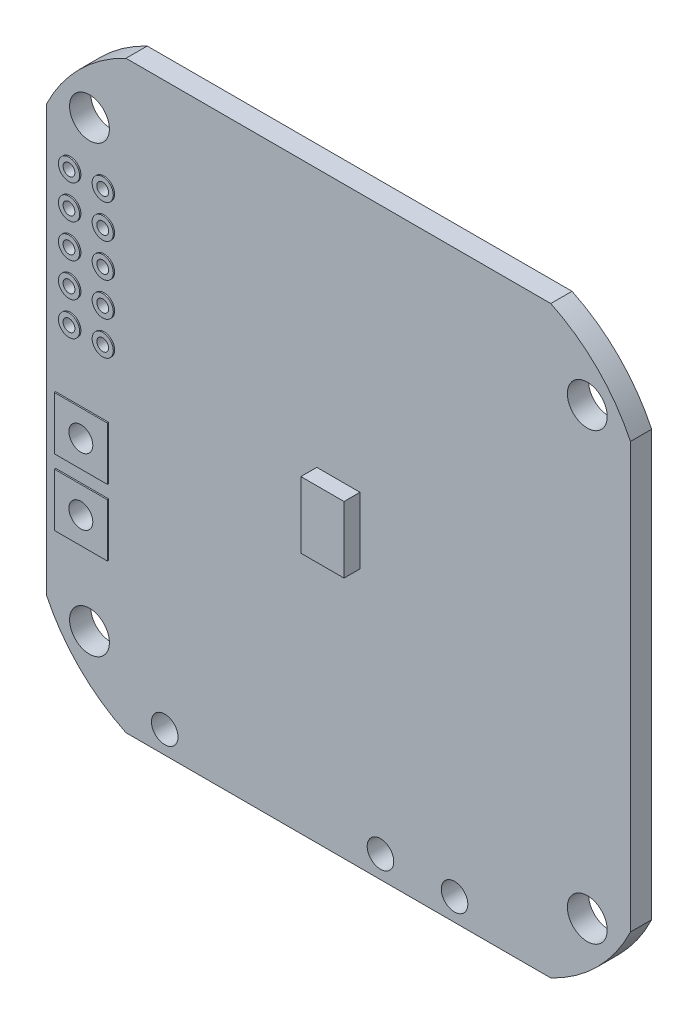
from build123d import *

# Parameters (mm, degrees)
SALIENTE_EXTRUIR1_DEPTH    = 0.8
CROQUIS2_R                 = 1.5
CORTAR_EXTRUIR1_DEPTH      = 2.6
CROQUIS3_W                 = 3.25
CROQUIS3_H                 = 5
SALIENTE_EXTRUIR2_DEPTH    = 1.2
CROQUIS4_R                 = 0.445
CORTAR_EXTRUIR2_DEPTH      = 3.8
CROQUIS5_R                 = 0.79739254
CROQUIS5_R_2               = 0.445
CROQUIS5_W                 = 4
CROQUIS5_H                 = 4
SALIENTE_EXTRUIR3_DEPTH    = 0.9
CROQUIS6_R                 = 0.9
CORTAR_EXTRUIR3_DEPTH      = 1
CORTAR_EXTRUIR3_DEPTH_BACK = 3.9
CROQUIS7_R                 = 1
CORTAR_EXTRUIR4_DEPTH      = 10
CROQUIS8_W                 = 3
CROQUIS8_H                 = 2.5
SALIENTE_EXTRUIR4_DEPTH    = 1.2
CROQUIS9_R                 = 0.75
SALIENTE_EXTRUIR5_DEPTH    = 0.8
CROQUIS10_W                = 5
CROQUIS10_H                = 5
SALIENTE_EXTRUIR6_DEPTH    = 0.9
CROQUIS11_R                = 1
SALIENTE_EXTRUIR7_DEPTH    = 0.1
SALIENTE_EXTRUIR8_DEPTH    = 0.75


with BuildPart() as part:
    # Croquis1 → Saliente-Extruir1 (new body, symmetric)
    with BuildSketch(Plane.XY):
        with BuildLine():
            Line((-22, 16), (-22, -16))
            ThreePointArc((-22, -16), (-19.513773424, -19.513773424), (-16, -22))
            Line((-16, -22), (16, -22))
            ThreePointArc((16, -22), (19.513773424, -19.513773424), (22, -16))
            Line((22, -16), (22, 16))
            ThreePointArc((22, 16), (19.513773424, 19.513773424), (16, 22))
            Line((16, 22), (-16, 22))
            ThreePointArc((-16, 22), (-19.513773424, 19.513773424), (-22, 16))
        make_face()
    extrude(amount=SALIENTE_EXTRUIR1_DEPTH, both=True)

    # Croquis2 → Cortar-Extruir1 (cut, through all)
    with BuildSketch(Plane.XY.offset(0.8)):
        with Locations((-18.75, 16.75)):
            Circle(CROQUIS2_R)
        with Locations((18.75, 16.75)):
            Circle(CROQUIS2_R)
        with Locations((18.75, -16.75)):
            Circle(CROQUIS2_R)
        with Locations((-18.75, -16.75)):
            Circle(CROQUIS2_R)
    extrude(amount=-CORTAR_EXTRUIR1_DEPTH, mode=Mode.SUBTRACT)

    # Croquis3 → Saliente-Extruir2 (add)
    with BuildSketch(Plane.XY.offset(0.8)):
        Rectangle(CROQUIS3_W, CROQUIS3_H)
    extrude(amount=SALIENTE_EXTRUIR2_DEPTH)

    # Croquis4 → Cortar-Extruir2 (cut, through all)
    with BuildSketch(Plane(origin=(0, 0, -0.8), x_dir=(-1, 0, 0), z_dir=(0, 0, -1))):
        with Locations((17.653, 12.7)):
            Circle(CROQUIS4_R)
        with Locations((20.193, 12.7)):
            Circle(CROQUIS4_R)
        with Locations((20.193, 10.16)):
            Circle(CROQUIS4_R)
        with Locations((20.193, 7.62)):
            Circle(CROQUIS4_R)
        with Locations((20.193, 5.08)):
            Circle(CROQUIS4_R)
        with Locations((20.193, 2.54)):
            Circle(CROQUIS4_R)
        with Locations((17.653, 10.16)):
            Circle(CROQUIS4_R)
        with Locations((17.653, 7.62)):
            Circle(CROQUIS4_R)
        with Locations((17.653, 5.08)):
            Circle(CROQUIS4_R)
        with Locations((17.653, 2.54)):
            Circle(CROQUIS4_R)
    extrude(amount=-CORTAR_EXTRUIR2_DEPTH, mode=Mode.SUBTRACT)

    # Croquis5 → Saliente-Extruir3 (add, symmetric)
    with BuildSketch(Plane.XY):
        with Locations((-17.653, 2.54)):
            Circle(CROQUIS5_R)
        with Locations((-17.653, 2.54)):
            Circle(CROQUIS5_R_2, mode=Mode.SUBTRACT)
        with Locations((-20.193, 2.54)):
            Circle(CROQUIS5_R)
        with Locations((-20.193, 2.54)):
            Circle(CROQUIS5_R_2, mode=Mode.SUBTRACT)
        with Locations((-20.193, 5.08)):
            Circle(CROQUIS5_R)
        with Locations((-20.193, 5.08)):
            Circle(CROQUIS5_R_2, mode=Mode.SUBTRACT)
        with Locations((-17.653, 5.08)):
            Circle(CROQUIS5_R)
        with Locations((-17.653, 5.08)):
            Circle(CROQUIS5_R_2, mode=Mode.SUBTRACT)
        with Locations((-17.653, 7.62)):
            Circle(CROQUIS5_R)
        with Locations((-17.653, 7.62)):
            Circle(CROQUIS5_R_2, mode=Mode.SUBTRACT)
        with Locations((-17.653, 10.16)):
            Circle(CROQUIS5_R)
        with Locations((-17.653, 10.16)):
            Circle(CROQUIS5_R_2, mode=Mode.SUBTRACT)
        with Locations((-20.193, 7.62)):
            Circle(CROQUIS5_R)
        with Locations((-20.193, 7.62)):
            Circle(CROQUIS5_R_2, mode=Mode.SUBTRACT)
        with Locations((-20.193, 10.16)):
            Circle(CROQUIS5_R)
        with Locations((-20.193, 10.16)):
            Circle(CROQUIS5_R_2, mode=Mode.SUBTRACT)
        with Locations((-17.653, 12.7)):
            Circle(CROQUIS5_R)
        with Locations((-17.653, 12.7)):
            Circle(CROQUIS5_R_2, mode=Mode.SUBTRACT)
        with Locations((-20.193, 12.7)):
            Circle(CROQUIS5_R)
        with Locations((-20.193, 12.7)):
            Circle(CROQUIS5_R_2, mode=Mode.SUBTRACT)
        with Locations((-19.3, -4.4)):
            Rectangle(CROQUIS5_W, CROQUIS5_H)
        with Locations((-19.3, -9.4)):
            Rectangle(CROQUIS5_W, CROQUIS5_H)
    extrude(amount=SALIENTE_EXTRUIR3_DEPTH, both=True)

    # Croquis6 → Cortar-Extruir3 (cut, two sides)
    with BuildSketch(Plane(origin=(0, 0, -0.9), x_dir=(-1, 0, 0), z_dir=(0, 0, -1))) as cortar_extruir3_sk:
        with Locations((19.3, -4.4)):
            Circle(CROQUIS6_R)
        with Locations((19.3, -9.4)):
            Circle(CROQUIS6_R)
    extrude(amount=CORTAR_EXTRUIR3_DEPTH, mode=Mode.SUBTRACT)
    extrude(cortar_extruir3_sk.sketch, amount=-CORTAR_EXTRUIR3_DEPTH_BACK, mode=Mode.SUBTRACT)

    # Croquis7 → Cortar-Extruir4 (cut)
    with BuildSketch(Plane(origin=(0, 0, -0.8), x_dir=(-1, 0, 0), z_dir=(0, 0, -1))):
        with Locations((-8.75, -20.32)):
            Circle(CROQUIS7_R)
        with Locations((-3.17, -20.32)):
            Circle(CROQUIS7_R)
        with Locations((13.08, -20.32)):
            Circle(CROQUIS7_R)
    extrude(amount=-CORTAR_EXTRUIR4_DEPTH, mode=Mode.SUBTRACT)

    # Croquis8 → Saliente-Extruir4 (add)
    with BuildSketch(Plane(origin=(0, 0, -0.8), x_dir=(-1, 0, 0), z_dir=(0, 0, -1))):
        with Locations((-19, 11.935)):
            Rectangle(CROQUIS8_W, CROQUIS8_H)
        with Locations((-19, 8.935)):
            Rectangle(CROQUIS8_W, CROQUIS8_H)
    extrude(amount=SALIENTE_EXTRUIR4_DEPTH)

    # Croquis9 → Saliente-Extruir5 (add)
    with BuildSketch(Plane(origin=(0, 0, -2), x_dir=(-1, 0, 0), z_dir=(0, 0, -1))):
        with Locations((-19, 11.935)):
            Circle(CROQUIS9_R)
        with Locations((-19, 8.935)):
            Circle(CROQUIS9_R)
    extrude(amount=SALIENTE_EXTRUIR5_DEPTH)

    # Croquis10 → Saliente-Extruir6 (add)
    with BuildSketch(Plane(origin=(0, 0, -0.8), x_dir=(-1, 0, 0), z_dir=(0, 0, -1))):
        with Locations((-13.5, -16.75)):
            Rectangle(CROQUIS10_W, CROQUIS10_H)
        with Locations((13.75, -14.7)):
            Rectangle(CROQUIS10_W, CROQUIS10_H)
        with Locations((8.387686328, -16.75)):
            Rectangle(CROQUIS10_W, CROQUIS10_H)
        with Locations((2.934297752, -16.75)):
            Rectangle(CROQUIS10_W, CROQUIS10_H)
        with Locations((-2.448267596, -14.7)):
            Rectangle(CROQUIS10_W, CROQUIS10_H)
        with Locations((-8.043302629, -14.7)):
            Rectangle(CROQUIS10_W, CROQUIS10_H)
    extrude(amount=SALIENTE_EXTRUIR6_DEPTH)

    # Croquis11 → Saliente-Extruir7 (add)
    with BuildSketch(Plane(origin=(0, 0, -0.8), x_dir=(-1, 0, 0), z_dir=(0, 0, -1))):
        Polygon((-13.652894244, -19.522521794), (-10.45933095, -19.522521794), (-9.812366284, -18.875557129), (-7.528981863, -18.875557129), (-7.147566948, -19.256972043), (-7.147566948, -21.343674777), (-7.528981863, -21.725089692), (-13.830102074, -21.725089692), (-14.141358707, -21.413833058), (-14.141358707, -20.010986258), align=None)
        with Locations((-8.75, -20.32)):
            Circle(CROQUIS11_R, mode=Mode.SUBTRACT)
        Polygon((8.172318821, -19.522521794), (11.198277852, -19.522521794), (12.022450347, -18.698349299), (14.296231203, -18.698349299), (14.77845979, -19.180577887), (14.77845979, -21.242861104), (14.296231203, -21.725089692), (7.995110992, -21.725089692), (7.683854358, -21.413833058), (7.683854358, -20.010986258), align=None)
        with Locations((13.08, -20.32)):
            Circle(CROQUIS11_R, mode=Mode.SUBTRACT)
        Polygon((2.263089361, -20.010986258), (1.774624897, -19.522521794), (-1.418938397, -19.522521794), (-2.065903062, -18.875557129), (-4.349287484, -18.875557129), (-4.730702399, -19.256972043), (-4.730702399, -21.343674777), (-4.349287484, -21.725089692), (1.951832727, -21.725089692), (2.263089361, -21.413833058), align=None)
        with Locations((-3.17, -20.32)):
            Circle(CROQUIS11_R, mode=Mode.SUBTRACT)
    extrude(amount=SALIENTE_EXTRUIR7_DEPTH)

    # Croquis12 → Saliente-Extruir8 (add)
    with BuildSketch(Plane(origin=(0, 0, -0.8), x_dir=(-1, 0, 0), z_dir=(0, 0, -1))):
        Polygon((-17.165976643, -2.501417361), (-10.881165522, -8.786228482), (-4.596354402, -2.501417361), (-10.881165522, 3.783393759), align=None)
    extrude(amount=SALIENTE_EXTRUIR8_DEPTH)


solid = part.part
